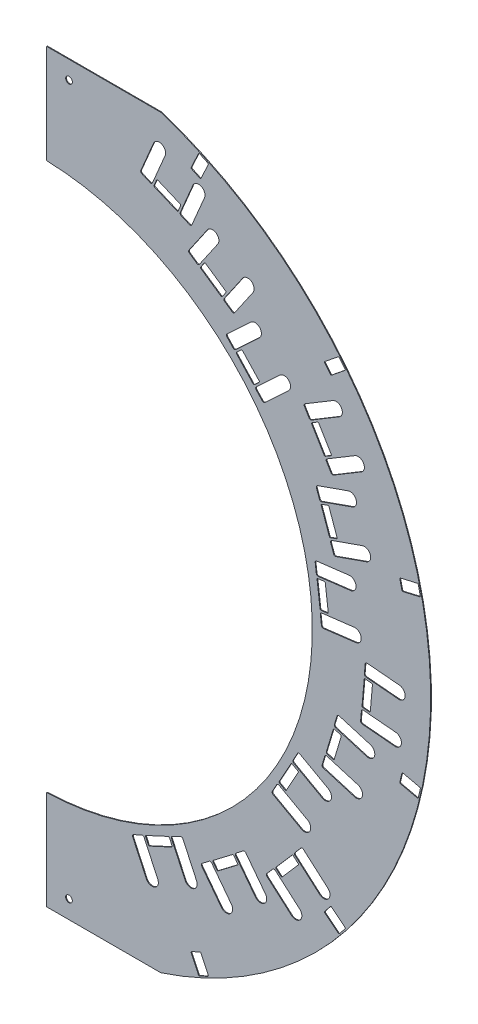
from build123d import *

# Parameters (mm, degrees)
EXTRUDE1_DEPTH                     = 0.205
EXTRUDE3_DEPTH                     = 1.41
CUT_EXTRUDE2_DEPTH                 = 1.41
CIRPATTERN2_COUNT                  = 6
CIRPATTERN2_ANGLE                  = 130
STAVE_MOUNT_HOLE_EXTRUDE5_DEPTH    = 1.41
MOUSE_HOLE_EXTRUDE7_DEPTH          = 1.205
STAVE_MOUNT_HOLE_CIRPATTERN3_COUNT = 4
STAVE_MOUNT_HOLE_CIRPATTERN3_ANGLE = 108.15757923
MOUSE_HOLE_CIRPATTERN5_COUNT       = 4
MOUSE_HOLE_CIRPATTERN5_ANGLE       = 108.15757923
SKETCH14_R                         = 1.85
CUT_EXTRUDE5_DEPTH                 = 1


with BuildPart() as part:
    # Sketch1 → Extrude1 (new body, symmetric)
    with BuildSketch(Plane.XY):
        with BuildLine():
            Line((4.5, 217.548779521), (4.5, 151.827758069))
            ThreePointArc((4.5, 151.827758069), (22.508034536, 150.217530607), (40.197176015, 146.479026351))
            ThreePointArc((40.197176015, 146.479026351), (151.89443084, 0), (40.197176015, -146.479026351))
            ThreePointArc((40.197176015, -146.479026351), (22.508034536, -150.217530607), (4.5, -151.827758069))
            Line((4.5, -151.827758069), (4.5, -217.548779521))
            ThreePointArc((4.5, -217.548779521), (217.59531583, 0), (4.5, 217.548779521))
        make_face()
    extrude(amount=EXTRUDE1_DEPTH, both=True)

    # Sketch3 → Extrude3 (cut, through all)
    with BuildSketch(Plane.XY.offset(0.205)):
        with BuildLine():
            Line((4.5, 217.548779521), (4.5, 206.75))
            Line((4.5, 206.75), (67.839214111, 206.75))
            ThreePointArc((67.839214111, 206.75), (36.570396283, 214.500180855), (4.5, 217.548779521))
        make_face()
        with BuildLine():
            Line((67.839214111, -206.75), (4.5, -206.75))
            Line((4.5, -206.75), (4.5, -217.548779521))
            ThreePointArc((4.5, -217.548779521), (36.570396283, -214.500180855), (67.839214111, -206.75))
        make_face()
    extrude(amount=-EXTRUDE3_DEPTH, mode=Mode.SUBTRACT)

    # Sketch7 → Cut-Extrude2 (cut, through all)
    with BuildSketch(Plane(origin=(0, 0, -0.205), x_dir=(-1, 0, 0), z_dir=(0, 0, -1))):
        with BuildLine():
            Line((-88.698900691, -197.314011122), (-84.684027204, -188.704087146))
            ThreePointArc((-84.684027204, -188.704087146), (-84.667334787, -188.321767943), (-84.925871967, -188.039624121))
            Line((-84.925871967, -188.039624121), (-89.457410902, -185.926532813))
            ThreePointArc((-89.457410902, -185.926532813), (-89.839730105, -185.909840396), (-90.121873926, -186.168377575))
            Line((-90.121873926, -186.168377575), (-94.136747413, -194.778301552))
            ThreePointArc((-94.136747413, -194.778301552), (-94.15343983, -195.160620755), (-93.89490265, -195.442764576))
            Line((-93.89490265, -195.442764576), (-89.363363715, -197.555855885))
            ThreePointArc((-89.363363715, -197.555855885), (-88.981044513, -197.572548302), (-88.698900691, -197.314011122))
        make_face()
    cut_extrude2 = extrude(amount=-CUT_EXTRUDE2_DEPTH, mode=Mode.SUBTRACT)

    # CirPattern2: Cut-Extrude2 ×6 about axis
    cirpattern2_axis = Axis((0, 0, 0), (0, 0, 1))
    for i in range(1, CIRPATTERN2_COUNT):
        add(cut_extrude2.rotate(cirpattern2_axis, i * CIRPATTERN2_ANGLE / (CIRPATTERN2_COUNT - 1)), mode=Mode.SUBTRACT)

    # Sketch12 → Stave Mount Hole Extrude5 (cut, through all)
    with BuildSketch(Plane.XY.offset(0.205)):
        with BuildLine():
            Line((78.554005798, 168.04877199), (66.124274411, 173.316767591))
            ThreePointArc((66.124274411, 173.316767591), (65.741603761, 173.319895419), (65.468803041, 173.051518117))
            Line((65.468803041, 173.051518117), (64.070247765, 169.751654614))
            ThreePointArc((64.070247765, 169.751654614), (64.067119936, 169.368983964), (64.335497238, 169.096183244))
            Line((64.335497238, 169.096183244), (76.765228625, 163.828187644))
            ThreePointArc((76.765228625, 163.828187644), (77.147899275, 163.825059815), (77.420699995, 164.093437117))
            Line((77.420699995, 164.093437117), (78.819255272, 167.393300621))
            ThreePointArc((78.819255272, 167.393300621), (78.8223831, 167.77597127), (78.554005798, 168.04877199))
        make_face()
        with BuildLine():
            Line((103.782710447, 138.874719717), (92.662330225, 146.52894363))
            ThreePointArc((92.662330225, 146.52894363), (92.288064798, 146.608768433), (91.966974516, 146.400567471))
            Line((91.966974516, 146.400567471), (89.934919812, 143.448312455))
            ThreePointArc((89.934919812, 143.448312455), (89.855095009, 143.074047027), (90.063295972, 142.752956746))
            Line((90.063295972, 142.752956746), (101.183676194, 135.098732832))
            ThreePointArc((101.183676194, 135.098732832), (101.557941621, 135.018908029), (101.879031902, 135.227108992))
            Line((101.879031902, 135.227108992), (103.911086607, 138.179364008))
            ThreePointArc((103.911086607, 138.179364008), (103.990911409, 138.553629435), (103.782710447, 138.874719717))
        make_face()
        with BuildLine():
            Line((122.392786555, 104.971179279), (113.182782772, 114.841631666))
            ThreePointArc((113.182782772, 114.841631666), (112.834507043, 115.000221154), (112.47609921, 114.866092726))
            Line((112.47609921, 114.866092726), (109.855676888, 112.421007277))
            ThreePointArc((109.855676888, 112.421007277), (109.6970874, 112.072731548), (109.831215828, 111.714323715))
            Line((109.831215828, 111.714323715), (119.041219611, 101.843871328))
            ThreePointArc((119.041219611, 101.843871328), (119.38949534, 101.685281841), (119.747903172, 101.819410269))
            Line((119.747903172, 101.819410269), (122.368325495, 104.264495717))
            ThreePointArc((122.368325495, 104.264495717), (122.526914983, 104.612771447), (122.392786555, 104.971179279))
        make_face()
    stave_mount_hole_extrude5 = extrude(amount=-STAVE_MOUNT_HOLE_EXTRUDE5_DEPTH, mode=Mode.SUBTRACT)

    # Sketch15 → Mouse Hole Extrude7 (cut, symmetric)
    with BuildSketch(Plane.XY):
        with BuildLine():
            Line((63.756596481, 189.833087254), (56.732602347, 173.260112071))
            ThreePointArc((56.732602347, 173.260112071), (56.72634669, 172.494770772), (57.263101294, 171.949169331))
            Line((57.263101294, 171.949169331), (61.866705512, 169.99805985))
            ThreePointArc((61.866705512, 169.99805985), (62.632046811, 169.991804192), (63.177648252, 170.528558797))
            Line((63.177648252, 170.528558797), (70.201642385, 187.10153398))
            ThreePointArc((70.201642385, 187.10153398), (68.34489607, 191.689833569), (63.756596481, 189.833087254))
        make_face()
        with BuildLine():
            Line((93.655811762, 163.184504516), (83.450179877, 148.357330887))
            ThreePointArc((83.450179877, 148.357330887), (83.290530271, 147.608800032), (83.706932196, 146.96661947))
            Line((83.706932196, 146.96661947), (87.825591537, 144.131721724))
            ThreePointArc((87.825591537, 144.131721724), (88.574122393, 143.972072118), (89.216302955, 144.388474043))
            Line((89.216302955, 144.388474043), (99.42193484, 159.215647672))
            ThreePointArc((99.42193484, 159.215647672), (98.523301723, 164.083137633), (93.655811762, 163.184504516))
        make_face()
        with BuildLine():
            Line((117.741552315, 130.891938027), (104.580949132, 118.611932984))
            ThreePointArc((104.580949132, 118.611932984), (104.263770157, 117.915381524), (104.532027013, 117.19856586))
            Line((104.532027013, 117.19856586), (107.943139525, 113.542842754))
            ThreePointArc((107.943139525, 113.542842754), (108.639690984, 113.225663778), (109.356506648, 113.493920635))
            Line((109.356506648, 113.493920635), (122.517109831, 125.773925678))
            ThreePointArc((122.517109831, 125.773925678), (122.688337248, 130.720710611), (117.741552315, 130.891938027))
        make_face()
        with BuildLine():
            Line((120.783733564, 101.247248228), (133.944336747, 113.527253271))
            ThreePointArc((133.944336747, 113.527253271), (138.89112168, 113.356025855), (138.719894263, 108.409240923))
            Line((138.719894263, 108.409240923), (125.55929108, 96.129235879))
            ThreePointArc((125.55929108, 96.129235879), (124.842475416, 95.860979023), (124.145923957, 96.178157998))
            Line((124.145923957, 96.178157998), (120.734811445, 99.833881105))
            ThreePointArc((120.734811445, 99.833881105), (120.466554589, 100.550696769), (120.783733564, 101.247248228))
        make_face()
        with BuildLine():
            Line((107.389223409, 130.665957432), (103.270564068, 133.500855177))
            ThreePointArc((103.270564068, 133.500855177), (102.854162143, 134.14303574), (103.013811749, 134.891566595))
            Line((103.013811749, 134.891566595), (113.219443634, 149.718740224))
            ThreePointArc((113.219443634, 149.718740224), (118.086933595, 150.617373341), (118.985566712, 145.74988338))
            Line((118.985566712, 145.74988338), (108.779934827, 130.922709751))
            ThreePointArc((108.779934827, 130.922709751), (108.137754265, 130.506307826), (107.389223409, 130.665957432))
        make_face()
        with BuildLine():
            Line((83.733825545, 160.730289812), (79.130221327, 162.681399294))
            ThreePointArc((79.130221327, 162.681399294), (78.593466723, 163.227000734), (78.59972238, 163.992342034))
            Line((78.59972238, 163.992342034), (85.623716514, 180.565317217))
            ThreePointArc((85.623716514, 180.565317217), (90.212016103, 182.422063532), (92.068762418, 177.833763942))
            Line((92.068762418, 177.833763942), (85.044768285, 161.26078876))
            ThreePointArc((85.044768285, 161.26078876), (84.499166844, 160.724034155), (83.733825545, 160.730289812))
        make_face()
    mouse_hole_extrude7 = extrude(amount=MOUSE_HOLE_EXTRUDE7_DEPTH, both=True, mode=Mode.SUBTRACT)

    # Stave Mount Hole CirPattern3: Stave Mount Hole Extrude5 ×4 about axis
    stave_mount_hole_cirpattern3_axis = Axis((0, 0, 0), (0, 0, -1))
    for i in range(1, STAVE_MOUNT_HOLE_CIRPATTERN3_COUNT):
        add(stave_mount_hole_extrude5.rotate(stave_mount_hole_cirpattern3_axis, i * STAVE_MOUNT_HOLE_CIRPATTERN3_ANGLE / (STAVE_MOUNT_HOLE_CIRPATTERN3_COUNT - 1)), mode=Mode.SUBTRACT)

    # Mouse Hole CirPattern5: Mouse Hole Extrude7 ×4 about axis
    mouse_hole_cirpattern5_axis = Axis((0, 0, 0), (0, 0, -1))
    for i in range(1, MOUSE_HOLE_CIRPATTERN5_COUNT):
        add(mouse_hole_extrude7.rotate(mouse_hole_cirpattern5_axis, i * MOUSE_HOLE_CIRPATTERN5_ANGLE / (MOUSE_HOLE_CIRPATTERN5_COUNT - 1)), mode=Mode.SUBTRACT)

    # Sketch14 → Cut-Extrude5 (cut)
    with BuildSketch(Plane.XY.offset(0.205)):
        with Locations((16.866246808, 196.75)):
            Circle(SKETCH14_R)
        with Locations((16.866246808, -196.75)):
            Circle(SKETCH14_R)
    extrude(amount=-CUT_EXTRUDE5_DEPTH, mode=Mode.SUBTRACT)


solid = part.part
